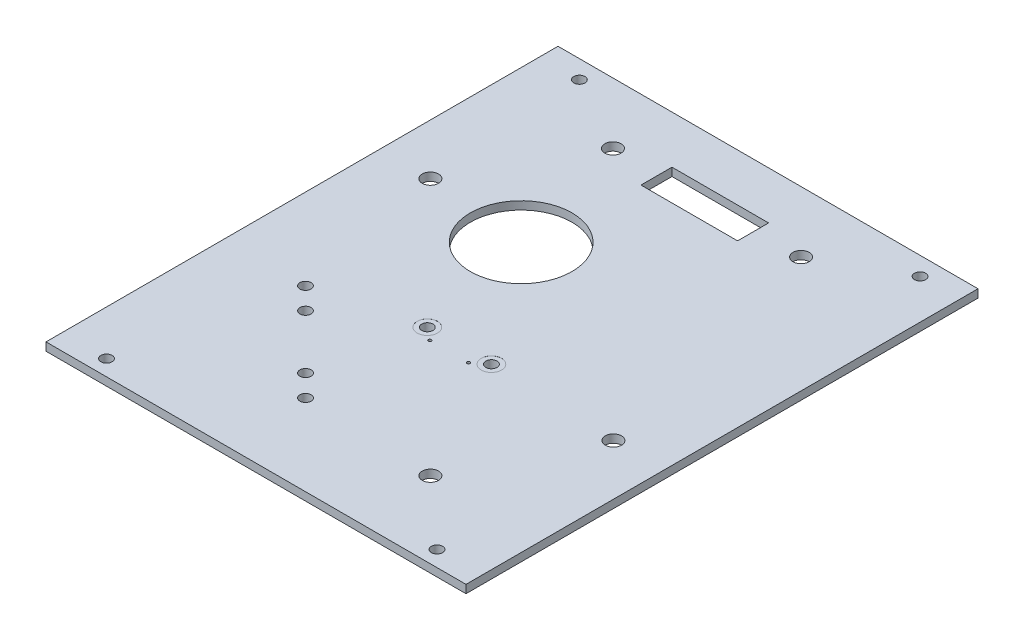
from build123d import *

# Parameters (mm, degrees)
BOSS_EXTRUDE1_DEPTH            = 1.6
F_2_2_2_2_DIAMETER_HOLE1_D     = 2.2
F_2_2_2_2_DIAMETER_HOLE1_DEPTH = 5
SKETCH9_R                      = 10
CUT_EXTRUDE4_DEPTH             = 2.6
SKETCH15_W                     = 83
SKETCH15_H                     = 2.5
CUT_EXTRUDE8_DEPTH             = 2.6
SKETCH37_W                     = 83
SKETCH37_H                     = 1.6
EXTRUDE1_DEPTH                 = 1.6
SKETCH38_W                     = 83
SKETCH38_H                     = 1.6
EXTRUDE2_DEPTH                 = 1.6
F_2_2_2_2_DIAMETER_HOLE4_D     = 2.2
F_2_2_2_2_DIAMETER_HOLE4_DEPTH = 1.6
SKETCH49_W                     = 0.2
SKETCH49_H                     = 100.7
EXTRUDE5_DEPTH                 = 2.6
SKETCH52_W                     = 19
SKETCH52_H                     = 6.1
CUT_EXTRUDE10_DEPTH            = 2.6
SKETCH_2_R                     = 1.6
CUT_EXTRUDE_2_DEPTH            = 10
SKETCH_8_R                     = 0.3
CUT_EXTRUDE_3_DEPTH            = 10
SKETCH_9_R                     = 1.1
CUT_EXTRUDE_4_DEPTH            = 10
SKETCH_10_R                    = 2
CUT_EXTRUDE_5_DEPTH            = 0.01
SKETCH_11_R                    = 1.1
CUT_EXTRUDE_6_DEPTH            = 10


with BuildPart() as part:
    # Sketch1 → Boss-Extrude1 (new body)
    with BuildSketch(Plane(origin=(0, 0, 0), x_dir=(1, 0, 0), z_dir=(0, 1, 0))):
        Polygon((65.24, 0.272495156), (65.24, -46.437452638), (65.24, -63.637452638), (65.24, -70.137452638), (-17.76, -70.137452638), (-17.76, -63.637452638), (-17.76, -48.637452638), (-17.76, -45.78978272), (-17.76, 4.362547362), (-17.76, 21.562547362), (-17.76, 29.862547362), (65.24, 29.862547362), (65.24, 21.562547362), (65.24, 6.562547362), align=None)
    extrude(amount=BOSS_EXTRUDE1_DEPTH)

    # Ø2.2 (2.2) Diameter Hole1
    with Locations(Plane(origin=(0, 1.6, 0), x_dir=(1, 0, 0), z_dir=(0, 1, 0))):
        with Locations((57.24, 27.862547362), (-9.76, 27.862547362)):
            Hole(F_2_2_2_2_DIAMETER_HOLE1_D / 2, depth=F_2_2_2_2_DIAMETER_HOLE1_DEPTH)

    # Sketch9 → Cut-Extrude4 (cut, through all)
    with BuildSketch(Plane(origin=(0, 0, 0), x_dir=(-1, 0, 0), z_dir=(0, -1, 0))):
        with Locations((-12.19, -5.537452638)):
            Circle(SKETCH9_R)
    extrude(amount=-CUT_EXTRUDE4_DEPTH, mode=Mode.SUBTRACT)

    # Sketch15 → Cut-Extrude8 (cut, through all)
    with BuildSketch(Plane.XZ):
        with Locations((23.74, 68.887452638)):
            Rectangle(SKETCH15_W, SKETCH15_H)
    extrude(amount=-CUT_EXTRUDE8_DEPTH, mode=Mode.SUBTRACT)

    # Sketch37 → Extrude1 (add)
    with BuildSketch(Plane(origin=(0, 0, -29.862547362), x_dir=(-1, 0, 0), z_dir=(0, 0, -1))):
        with Locations((-23.74, 0.8)):
            Rectangle(SKETCH37_W, SKETCH37_H)
    extrude(amount=EXTRUDE1_DEPTH)

    # Sketch38 → Extrude2 (add)
    with BuildSketch(Plane.XY.offset(67.637452638)):
        with Locations((23.74, 0.8)):
            Rectangle(SKETCH38_W, SKETCH38_H)
    extrude(amount=EXTRUDE2_DEPTH)

    # Ø2.2 (2.2) Diameter Hole4
    with Locations(Plane(origin=(0, 1.6, 0), x_dir=(1, 0, 0), z_dir=(0, 1, 0))):
        with Locations((-8.76, -66.137452638), (56.24, -66.137452638)):
            Hole(F_2_2_2_2_DIAMETER_HOLE4_D / 2, depth=F_2_2_2_2_DIAMETER_HOLE4_DEPTH)

    # Sketch49 → Extrude5 (cut, through all)
    with BuildSketch(Plane.XZ):
        with Locations((65.14, 18.887452638)):
            Rectangle(SKETCH49_W, SKETCH49_H)
        with Locations((-17.66, 18.887452638)):
            Rectangle(SKETCH49_W, SKETCH49_H)
    extrude(amount=-EXTRUDE5_DEPTH, mode=Mode.SUBTRACT)

    # Sketch52 → Cut-Extrude10 (cut, through all)
    with BuildSketch(Plane.XZ):
        with Locations((23.74, -19.027547362)):
            Rectangle(SKETCH52_W, SKETCH52_H)
    extrude(amount=-CUT_EXTRUDE10_DEPTH, mode=Mode.SUBTRACT)

    # ｽｹｯﾁ2 → ｶｯﾄ - 押し出し2 (cut)
    with BuildSketch(Plane(origin=(0, 0, 0), x_dir=(-1, 0, 0), z_dir=(0, -1, 0))):
        with Locations((-55.04, -30.237452638)):
            Circle(SKETCH_2_R)
        with Locations((7.56, -3.637452638)):
            Circle(SKETCH_2_R)
        with Locations((-42.24, 19.462547362)):
            Circle(SKETCH_2_R)
        with Locations((-5.24, 19.462547362)):
            Circle(SKETCH_2_R)
        with Locations((-43.04, -54.237452638)):
            Circle(SKETCH_2_R)
    extrude(amount=-CUT_EXTRUDE_2_DEPTH, mode=Mode.SUBTRACT)

    # ｽｹｯﾁ8 → ｶｯﾄ - 押し出し3 (cut)
    with BuildSketch(Plane(origin=(0, 1.6, 0), x_dir=(1, 0, 0), z_dir=(0, 1, 0))):
        with Locations((27.54, -31.237452638)):
            Circle(SKETCH_8_R)
        with Locations((19.94, -31.237452638)):
            Circle(SKETCH_8_R)
    extrude(amount=-CUT_EXTRUDE_3_DEPTH, mode=Mode.SUBTRACT)

    # ｽｹｯﾁ9 → ｶｯﾄ - 押し出し4 (cut)
    with BuildSketch(Plane(origin=(0, 1.6, 0), x_dir=(1, 0, 0), z_dir=(0, 1, 0))):
        with Locations((30.04, -29.237452638)):
            Circle(SKETCH_9_R)
        with Locations((17.44, -29.237452638)):
            Circle(SKETCH_9_R)
    extrude(amount=-CUT_EXTRUDE_4_DEPTH, mode=Mode.SUBTRACT)

    # ｽｹｯﾁ10 → ｶｯﾄ - 押し出し5 (cut)
    with BuildSketch(Plane(origin=(0, 1.6, 0), x_dir=(1, 0, 0), z_dir=(0, 1, 0))):
        with Locations((30.04, -29.237452638)):
            Circle(SKETCH_10_R)
        with Locations((17.44, -29.237452638)):
            Circle(SKETCH_10_R)
    extrude(amount=-CUT_EXTRUDE_5_DEPTH, mode=Mode.SUBTRACT)

    # ｽｹｯﾁ11 → ｶｯﾄ - 押し出し6 (cut)
    with BuildSketch(Plane.XZ):
        with Locations((17.512640687, 53.270093325)):
            Circle(SKETCH_11_R)
        with Locations((13.27, 49.027452638)):
            Circle(SKETCH_11_R)
        with Locations((2.66, 38.417452638)):
            Circle(SKETCH_11_R)
        with Locations((-1.587634962, 34.179812111)):
            Circle(SKETCH_11_R)
    extrude(amount=-CUT_EXTRUDE_6_DEPTH, mode=Mode.SUBTRACT)


solid = part.part
